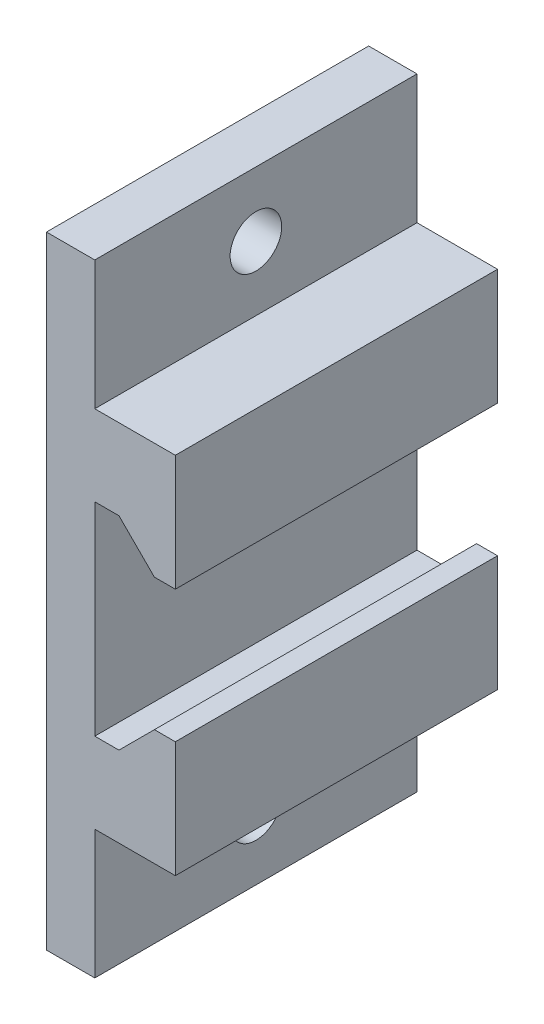
from build123d import *

# Parameters (mm, degrees)
MAIN_DEPTH         = 10
SKETCH2_R          = 1.6
CUT_EXTRUDE1_DEPTH = 4


with BuildPart() as part:
    # Sketch1 → Main (new body, symmetric)
    with BuildSketch(Plane.XY):
        Polygon((0, 19.3), (0, -19.3), (3, -19.3), (3, -11.3), (8, -11.3), (8, -4.1), (6.7, -4.1), (4.5, -6.3), (3, -6.3), (3, 6.3), (4.5, 6.3), (6.7, 4.1), (8, 4.1), (8, 11.3), (3, 11.3), (3, 19.3), align=None)
    extrude(amount=MAIN_DEPTH, both=True)

    # Sketch2 → Cut-Extrude1 (cut, through all)
    with BuildSketch(Plane(origin=(3, 0, 0), x_dir=(0, 0, -1), z_dir=(1, 0, 0))):
        with Locations((0, 15.3)):
            Circle(SKETCH2_R)
        with Locations((0, -15.3)):
            Circle(SKETCH2_R)
    extrude(amount=-CUT_EXTRUDE1_DEPTH, mode=Mode.SUBTRACT)


solid = part.part
